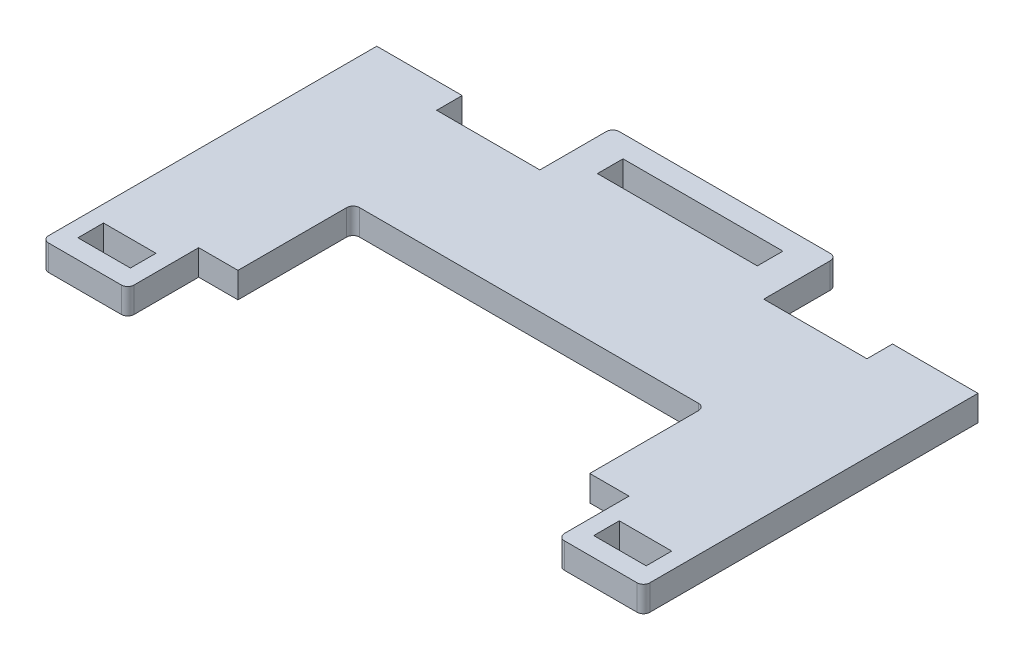
from build123d import *

# Parameters (mm, degrees)
SKETCH1_W            = 8.2
SKETCH1_H            = 4
BOSS_EXTRUDE1_DEPTH  = 4
FILLET1_R            = 1
FILLET1_OF_MIRROR1_R = 1


with BuildPart() as part:
    # Sketch1 → Boss-Extrude1 (new body)
    with BuildSketch(Plane(origin=(0, 0, 0), x_dir=(1, 0, 0), z_dir=(0, 1, 0))):
        Polygon((0, 52.3), (0, 0), (13.36, 0), (13.36, 11.1), (19.5, 11.1), (19.5, 29.1), (47, 29.1), (47, 52.3), (34.5, 52.3), (34.5, 56.3), (47, 56.3), (47, 59.7), (29.5, 59.7), (29.5, 48.3), (13.36, 48.3), (13.36, 52.3), align=None)
        with Locations((6.68, 5)):
            Rectangle(SKETCH1_W, SKETCH1_H, mode=Mode.SUBTRACT)
    boss_extrude1 = extrude(amount=BOSS_EXTRUDE1_DEPTH)

    # Fillet1
    fillet1_edges = [part.edges().sort_by_distance(p)[0] for p in [
        (19.5, 2, -29.1),
        (13.36, 2, 0),
        (0, 2, 0),
        (29.5, 2, -59.7),
    ]]
    fillet(fillet1_edges, radius=FILLET1_R)

    # Mirror1: Boss-Extrude1 across plane
    add(boss_extrude1.mirror(Plane(origin=(47, 4, 0), x_dir=(0, 0, 1), z_dir=(1, 0, 0))))

    # Fillet1 of Mirror1
    fillet1_of_mirror1_edges = [part.edges().sort_by_distance(p)[0] for p in [
        (74.5, 2, -29.1),
        (80.64, 2, 0),
        (94, 2, 0),
        (64.5, 2, -59.7),
    ]]
    fillet(fillet1_of_mirror1_edges, radius=FILLET1_OF_MIRROR1_R)


solid = part.part
